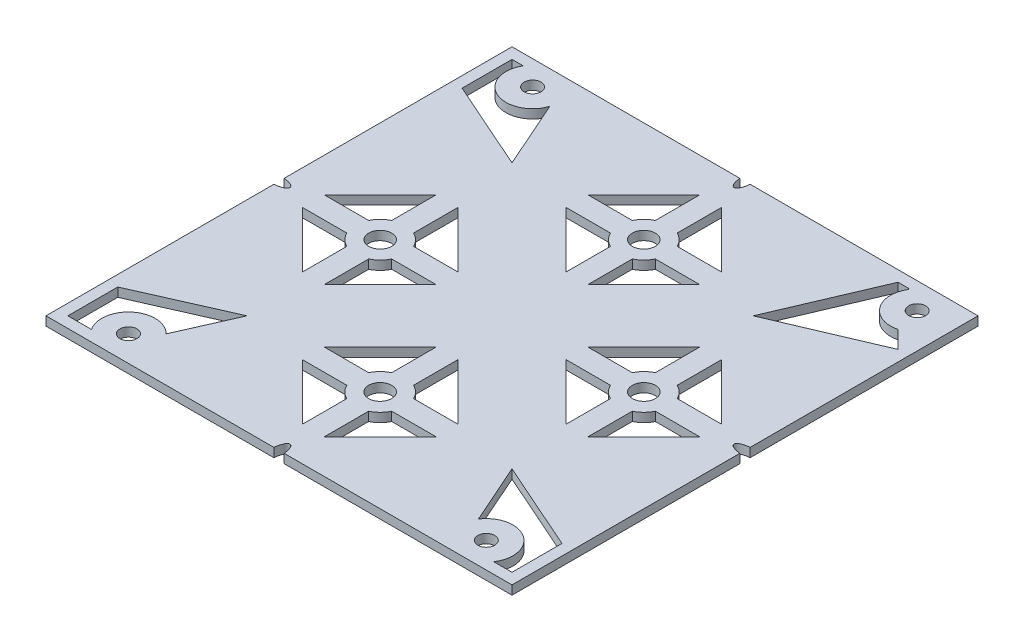
from build123d import *

# Parameters (mm, degrees)
SKETCH1_W           = 97.6
SKETCH1_H           = 97.6
BOSS_EXTRUDE1_DEPTH = 1.85
SKETCH3_R           = 1.25
CUT_EXTRUDE1_DEPTH  = 10
FILLET1_R           = 0.2
SKETCH5_R           = 2.375
CUT_EXTRUDE2_DEPTH  = 10
SKETCH6_R           = 1.75
CUT_EXTRUDE3_DEPTH  = 2.8500001
SKETCH7_W           = 97.6
SKETCH7_H           = 1.85
CUT_EXTRUDE4_DEPTH  = 0.75
SKETCH8_W           = 96.85
SKETCH8_H           = 1.85
CUT_EXTRUDE5_DEPTH  = 0.75
SKETCH9_W           = 96.85
SKETCH9_H           = 1.85
CUT_EXTRUDE6_DEPTH  = 0.75
SKETCH12_W          = 96.1
SKETCH12_H          = 1.85
CUT_EXTRUDE7_DEPTH  = 0.75


with BuildPart() as part:
    # Sketch1 → Boss-Extrude1 (new body)
    with BuildSketch(Plane(origin=(0, 0, 0), x_dir=(1, 0, 0), z_dir=(0, 1, 0))):
        with Locations((48.8, 48.8)):
            Rectangle(SKETCH1_W, SKETCH1_H)
    extrude(amount=BOSS_EXTRUDE1_DEPTH)

    # Sketch3 → Cut-Extrude1 (cut)
    with BuildSketch(Plane.XZ):
        with BuildLine():
            Line((3, -84.3), (3, -94.6))
            Line((3, -94.6), (5.316079849, -94.6))
            ThreePointArc((5.316079849, -94.6), (7.792729855, -86.784550719), (15.285000001, -90.113353923))
            Line((15.285000001, -90.113353923), (21.472818771, -76.127181229))
            Line((21.472818771, -76.127181229), (3, -84.3))
        make_face()
        with BuildLine():
            Line((3, -13.3), (21.472818771, -21.472818771))
            Line((21.472818771, -21.472818771), (16.360495139, -9.917560959))
            ThreePointArc((16.360495139, -9.917560959), (8.975209709, -10.313312378), (7.873156109, -3))
            Line((7.873156109, -3), (3, -3))
            Line((3, -3), (3, -13.3))
        make_face()
        with BuildLine():
            Line((94.6, -13.3), (94.6, -3))
            Line((94.6, -3), (90.826843891, -3))
            ThreePointArc((90.826843891, -3), (89.267333256, -10.648445392), (81.630186258, -9.034513526))
            Line((81.630186258, -9.034513526), (76.127181229, -21.472818771))
            Line((76.127181229, -21.472818771), (94.6, -13.3))
        make_face()
        with BuildLine():
            Line((91.027327292, -86.172672708), (94.6, -82.6))
            Line((94.6, -82.6), (73.674141566, -73.674141566))
            Line((73.674141566, -73.674141566), (82.6, -94.6))
            Line((82.6, -94.6), (85.116873323, -94.6))
            ThreePointArc((85.116873323, -94.6), (85.157069093, -88.341897208), (91.027327292, -86.172672708))
        make_face()
        with Locations((89.66, -91.5)):
            Circle(SKETCH3_R)
        with Locations((10.05, -91.8)):
            Circle(SKETCH3_R)
        with Locations((12.45, -6.05)):
            Circle(SKETCH3_R)
        with Locations((86.25, -6.05)):
            Circle(SKETCH3_R)
    extrude(amount=-CUT_EXTRUDE1_DEPTH, mode=Mode.SUBTRACT)

    # Fillet1
    fillet1_edges = [part.edges().sort_by_distance(p)[0] for p in [
        (85.116873323, 0.925, -94.6),
    ]]
    fillet(fillet1_edges, radius=FILLET1_R)

    # Sketch5 → Cut-Extrude2 (cut)
    with BuildSketch(Plane.XZ):
        with BuildLine():
            Line((51.05, -80.617052601), (51.05, -89.767052601))
            Line((51.05, -89.767052601), (62.582493929, -78.234558673))
            Line((62.582493929, -78.234558673), (53.432493929, -78.234558673))
            ThreePointArc((53.432493929, -78.234558673), (52.441599923, -79.626158596), (51.05, -80.617052601))
        make_face()
        with BuildLine():
            Line((46.55, -89.767052601), (46.55, -80.617052601))
            ThreePointArc((46.55, -80.617052601), (45.158400077, -79.626158596), (44.167506071, -78.234558673))
            Line((44.167506071, -78.234558673), (35.017506071, -78.234558673))
            Line((35.017506071, -78.234558673), (46.55, -89.767052601))
        make_face()
        with Locations((48.8, -75.984558673)):
            Circle(SKETCH5_R)
        with BuildLine():
            ThreePointArc((51.05, -71.352064744), (52.441599923, -72.34295875), (53.432493929, -73.734558673))
            Line((53.432493929, -73.734558673), (62.582493929, -73.734558673))
            Line((62.582493929, -73.734558673), (51.05, -62.202064744))
            Line((51.05, -62.202064744), (51.05, -71.352064744))
        make_face()
        with BuildLine():
            Line((35.017506071, -73.734558673), (44.167506071, -73.734558673))
            ThreePointArc((44.167506071, -73.734558673), (45.158400077, -72.34295875), (46.55, -71.352064744))
            Line((46.55, -71.352064744), (46.55, -62.202064744))
            Line((46.55, -62.202064744), (35.017506071, -73.734558673))
        make_face()
        with BuildLine():
            Line((19.365441327, -62.582493929), (19.365441327, -53.432493929))
            ThreePointArc((19.365441327, -53.432493929), (17.973841404, -52.441599923), (16.982947399, -51.05))
            Line((16.982947399, -51.05), (7.832947399, -51.05))
            Line((7.832947399, -51.05), (19.365441327, -62.582493929))
        make_face()
        with BuildLine():
            Line((23.865441327, -62.582493929), (35.397935256, -51.05))
            Line((35.397935256, -51.05), (26.247935256, -51.05))
            ThreePointArc((26.247935256, -51.05), (25.25704125, -52.441599923), (23.865441327, -53.432493929))
            Line((23.865441327, -53.432493929), (23.865441327, -62.582493929))
        make_face()
        with BuildLine():
            ThreePointArc((23.865441327, -44.167506071), (25.25704125, -45.158400077), (26.247935256, -46.55))
            Line((26.247935256, -46.55), (35.397935256, -46.55))
            Line((35.397935256, -46.55), (23.865441327, -35.017506071))
            Line((23.865441327, -35.017506071), (23.865441327, -44.167506071))
        make_face()
        with BuildLine():
            Line((7.832947399, -46.55), (16.982947399, -46.55))
            ThreePointArc((16.982947399, -46.55), (17.973841404, -45.158400077), (19.365441327, -44.167506071))
            Line((19.365441327, -44.167506071), (19.365441327, -35.017506071))
            Line((19.365441327, -35.017506071), (7.832947399, -46.55))
        make_face()
        with Locations((21.615441327, -48.8)):
            Circle(SKETCH5_R)
        with Locations((75.984558673, -48.8)):
            Circle(SKETCH5_R)
        with BuildLine():
            ThreePointArc((80.617052601, -51.05), (79.626158596, -52.441599923), (78.234558673, -53.432493929))
            Line((78.234558673, -53.432493929), (78.234558673, -62.582493929))
            Line((78.234558673, -62.582493929), (89.767052601, -51.05))
            Line((89.767052601, -51.05), (80.617052601, -51.05))
        make_face()
        with BuildLine():
            ThreePointArc((73.734558673, -53.432493929), (72.34295875, -52.441599923), (71.352064744, -51.05))
            Line((71.352064744, -51.05), (62.202064744, -51.05))
            Line((62.202064744, -51.05), (73.734558673, -62.582493929))
            Line((73.734558673, -62.582493929), (73.734558673, -53.432493929))
        make_face()
        with BuildLine():
            Line((73.734558673, -35.017506071), (62.202064744, -46.55))
            Line((62.202064744, -46.55), (71.352064744, -46.55))
            ThreePointArc((71.352064744, -46.55), (72.34295875, -45.158400077), (73.734558673, -44.167506071))
            Line((73.734558673, -44.167506071), (73.734558673, -35.017506071))
        make_face()
        with BuildLine():
            Line((78.234558673, -35.017506071), (78.234558673, -44.167506071))
            ThreePointArc((78.234558673, -44.167506071), (79.626158596, -45.158400077), (80.617052601, -46.55))
            Line((80.617052601, -46.55), (89.767052601, -46.55))
            Line((89.767052601, -46.55), (78.234558673, -35.017506071))
        make_face()
        with BuildLine():
            Line((46.55, -16.982947399), (46.55, -7.832947399))
            Line((46.55, -7.832947399), (35.017506071, -19.365441327))
            Line((35.017506071, -19.365441327), (44.167506071, -19.365441327))
            ThreePointArc((44.167506071, -19.365441327), (45.158400077, -17.973841404), (46.55, -16.982947399))
        make_face()
        with BuildLine():
            Line((51.05, -7.832947399), (51.05, -16.982947399))
            ThreePointArc((51.05, -16.982947399), (52.441599923, -17.973841404), (53.432493929, -19.365441327))
            Line((53.432493929, -19.365441327), (62.582493929, -19.365441327))
            Line((62.582493929, -19.365441327), (51.05, -7.832947399))
        make_face()
        with BuildLine():
            Line((62.582493929, -23.865441327), (53.432493929, -23.865441327))
            ThreePointArc((53.432493929, -23.865441327), (52.441599923, -25.25704125), (51.05, -26.247935256))
            Line((51.05, -26.247935256), (51.05, -35.397935256))
            Line((51.05, -35.397935256), (62.582493929, -23.865441327))
        make_face()
        with BuildLine():
            ThreePointArc((46.55, -26.247935256), (45.158400077, -25.25704125), (44.167506071, -23.865441327))
            Line((44.167506071, -23.865441327), (35.017506071, -23.865441327))
            Line((35.017506071, -23.865441327), (46.55, -35.397935256))
            Line((46.55, -35.397935256), (46.55, -26.247935256))
        make_face()
        with BuildLine():
            add(Edge.make_bspline(
                [(47.7, -97.6), (47.7, -100.595404627), (48.8, -100.595404627), (49.9, -100.595404627), (49.9, -97.6)],
                knots=[1.570796327, 1.570796327, 1.570796327, 3.141592654, 3.141592654, 4.71238898, 4.71238898, 4.71238898], degree=2, weights=[1, 0.707106781, 1, 0.707106781, 1]))
            Line((49.9, -97.6), (47.7, -97.6))
        make_face()
        with BuildLine():
            Line((47.7, -97.6), (49.9, -97.6))
            add(Edge.make_bspline(
                [(49.9, -97.6), (49.9, -94.604595373), (48.8, -94.604595373)],
                knots=[4.71238898, 4.71238898, 4.71238898, 6.283185307, 6.283185307, 6.283185307], degree=2, weights=[1, 0.707106781, 1]))
            add(Edge.make_bspline(
                [(48.8, -94.604595373), (47.7, -94.604595373), (47.7, -97.6)],
                knots=[0, 0, 0, 1.570796327, 1.570796327, 1.570796327], degree=2, weights=[1, 0.707106781, 1]))
        make_face()
        with BuildLine():
            add(Edge.make_bspline(
                [(48.8, -3), (49.9, -3), (49.9, 0)],
                knots=[0, 0, 0, 1.570796327, 1.570796327, 1.570796327], degree=2, weights=[1, 0.707106781, 1]))
            Line((49.9, 0), (48.8, 0))
            Line((48.8, 0), (47.7, 0))
            add(Edge.make_bspline(
                [(47.7, 0), (47.7, -3), (48.8, -3)],
                knots=[4.71238898, 4.71238898, 4.71238898, 6.283185307, 6.283185307, 6.283185307], degree=2, weights=[1, 0.707106781, 1]))
        make_face()
        with BuildLine():
            Line((48.8, 0), (49.9, 0))
            add(Edge.make_bspline(
                [(49.9, 0), (49.9, 3), (48.8, 3), (47.7, 3), (47.7, 0)],
                knots=[1.570796327, 1.570796327, 1.570796327, 3.141592654, 3.141592654, 4.71238898, 4.71238898, 4.71238898], degree=2, weights=[1, 0.707106781, 1, 0.707106781, 1]))
            Line((47.7, 0), (48.8, 0))
        make_face()
        with BuildLine():
            add(Edge.make_bspline(
                [(94.596161078, -48.8), (94.596161078, -49.9), (97.6, -49.9)],
                knots=[0, 0, 0, 1.570796327, 1.570796327, 1.570796327], degree=2, weights=[1, 0.707106781, 1]))
            Line((97.6, -49.9), (97.6, -48.8))
            Line((97.6, -48.8), (97.6, -47.7))
            add(Edge.make_bspline(
                [(97.6, -47.7), (94.596161078, -47.7), (94.596161078, -48.8)],
                knots=[4.71238898, 4.71238898, 4.71238898, 6.283185307, 6.283185307, 6.283185307], degree=2, weights=[1, 0.707106781, 1]))
        make_face()
        with BuildLine():
            Line((97.6, -48.8), (97.6, -49.9))
            add(Edge.make_bspline(
                [(97.6, -49.9), (100.603838922, -49.9), (100.603838922, -48.8), (100.603838922, -47.7), (97.6, -47.7)],
                knots=[1.570796327, 1.570796327, 1.570796327, 3.141592654, 3.141592654, 4.71238898, 4.71238898, 4.71238898], degree=2, weights=[1, 0.707106781, 1, 0.707106781, 1]))
            Line((97.6, -47.7), (97.6, -48.8))
        make_face()
        with BuildLine():
            add(Edge.make_bspline(
                [(0, -47.7), (-3, -47.7), (-3, -48.8), (-3, -49.9), (0, -49.9)],
                knots=[1.570796327, 1.570796327, 1.570796327, 3.141592654, 3.141592654, 4.71238898, 4.71238898, 4.71238898], degree=2, weights=[1, 0.707106781, 1, 0.707106781, 1]))
            Line((0, -49.9), (0, -48.8))
            Line((0, -48.8), (0, -47.7))
        make_face()
        with BuildLine():
            Line((0, -48.8), (0, -49.9))
            add(Edge.make_bspline(
                [(0, -49.9), (3, -49.9), (3, -48.8)],
                knots=[4.71238898, 4.71238898, 4.71238898, 6.283185307, 6.283185307, 6.283185307], degree=2, weights=[1, 0.707106781, 1]))
            add(Edge.make_bspline(
                [(3, -48.8), (3, -47.7), (0, -47.7)],
                knots=[0, 0, 0, 1.570796327, 1.570796327, 1.570796327], degree=2, weights=[1, 0.707106781, 1]))
            Line((0, -47.7), (0, -48.8))
        make_face()
        with Locations((48.8, -21.615441327)):
            Circle(SKETCH5_R)
    extrude(amount=-CUT_EXTRUDE2_DEPTH, mode=Mode.SUBTRACT)

    # Sketch6 → Cut-Extrude3 (cut, through all)
    with BuildSketch(Plane.XZ):
        with Locations((12.45, -6.05)):
            Circle(SKETCH6_R)
        with Locations((86.25, -6.05)):
            Circle(SKETCH6_R)
        with Locations((10.05, -91.8)):
            Circle(SKETCH6_R)
        with Locations((89.66, -91.5)):
            Circle(SKETCH6_R)
    extrude(amount=-CUT_EXTRUDE3_DEPTH, mode=Mode.SUBTRACT)

    # Sketch7 → Cut-Extrude4 (cut)
    with BuildSketch(Plane(origin=(0, 0, -97.6), x_dir=(-1, 0, 0), z_dir=(0, 0, -1))):
        with Locations((-48.8, 0.925)):
            Rectangle(SKETCH7_W, SKETCH7_H)
    extrude(amount=-CUT_EXTRUDE4_DEPTH, mode=Mode.SUBTRACT)

    # Sketch8 → Cut-Extrude5 (cut)
    with BuildSketch(Plane(origin=(97.6, 0, 0), x_dir=(0, 0, -1), z_dir=(1, 0, 0))):
        with Locations((48.425, 0.925)):
            Rectangle(SKETCH8_W, SKETCH8_H)
    extrude(amount=-CUT_EXTRUDE5_DEPTH, mode=Mode.SUBTRACT)

    # Sketch9 → Cut-Extrude6 (cut)
    with BuildSketch(Plane.XY):
        with Locations((48.425, 0.925)):
            Rectangle(SKETCH9_W, SKETCH9_H)
    extrude(amount=-CUT_EXTRUDE6_DEPTH, mode=Mode.SUBTRACT)

    # Sketch12 → Cut-Extrude7 (cut)
    with BuildSketch(Plane.ZY):
        with Locations((-48.8, 0.925)):
            Rectangle(SKETCH12_W, SKETCH12_H)
    extrude(amount=-CUT_EXTRUDE7_DEPTH, mode=Mode.SUBTRACT)


solid = part.part
